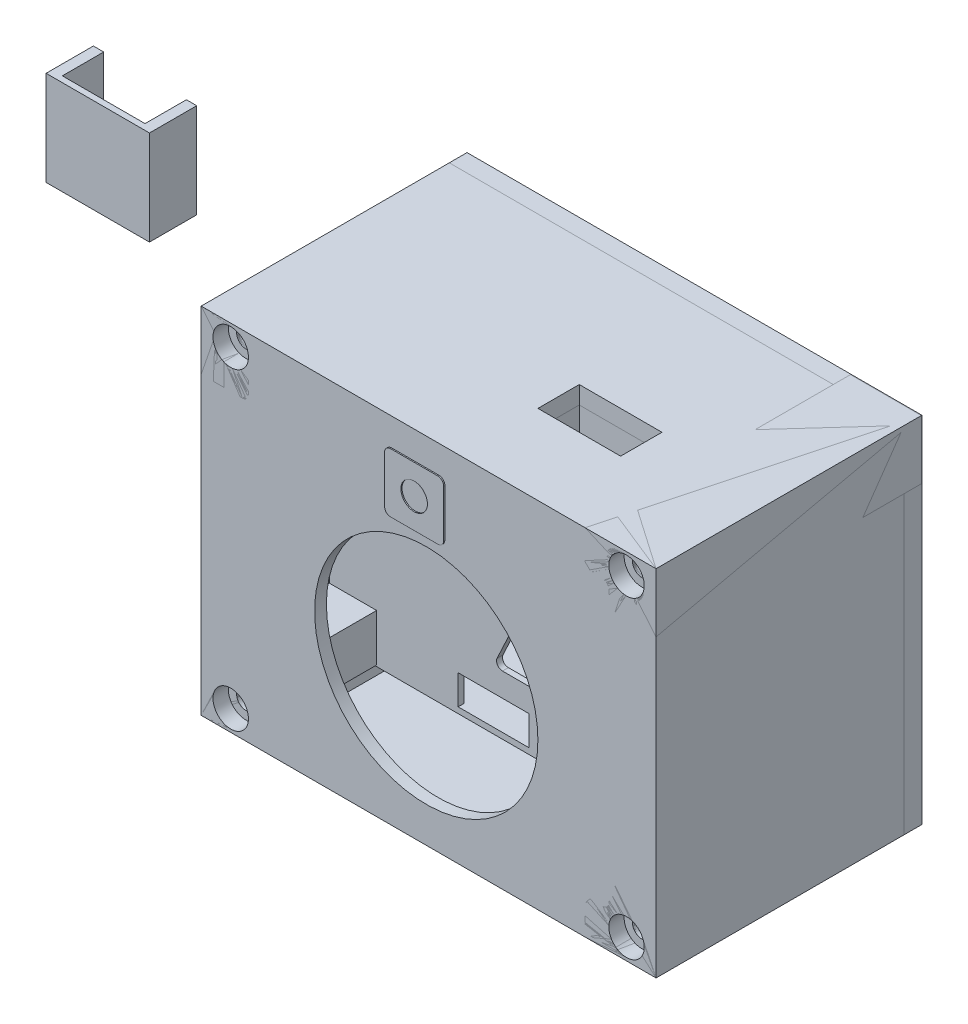
from build123d import *

# Parameters (mm, degrees)
NODEBASESECTION_W                   = 48.4
NODEBASESECTION_H                   = 25.7
NODEBASE_DEPTH                      = 1.7
WIFIMODEMSECTION_W                  = 15
WIFIMODEMSECTION_H                  = 12
WIFIMODEMSECTION_W_2                = 5.7
WIFIMODEMSECTION_H_2                = 7.4
MICROPORT_WIFIMODEM_DEPTH           = 2.7
ANTENNA_DEPTH                       = 0.2
F_4NODEATTACHMENTHOLESSECTION_R     = 1.5
F_4NODEATTACHMENTHOLES_DEPTH        = 2
DSMBLUEPINSSECTION_W                = 6
DSMBLUEPINSSECTION_H                = 6
DSMBLUEPINS_DEPTH                   = 5
DSMBLUEPINS_2_DEPTH                 = 5
PCBSECTION_W                        = 58.8
PCBSECTION_H                        = 44.55
PCB_DEPTH                           = 1.5
BLACKPLASTICCOVER_DEPTH             = 15
BLACKDSMSHELL_T                     = -1
SIDEHOLECUTTERSECTION_W             = 14
SIDEHOLECUTTERSECTION_H             = 7
SIDEHOLECUTTER_DEPTH                = 1.5
F_3HOLESCUTTERSECTION_W             = 12
F_3HOLESCUTTERSECTION_H             = 5
F_3HOLESCUTTER_DEPTH                = 1.5
BOXCAP_TONODE_START                 = -9
BOXCAPSECTION_TONODE_W              = 77
BOXCAPSECTION_TONODE_H              = 60
BOXCAP_TONODE_DEPTH                 = 3
NODESCREWCOLUMNSSECTION_W           = 8
NODESCREWCOLUMNSSECTION_H           = 8
NODESCREWCOLUMNS_DEPTH              = 6
BOXCAP_TODSM_START                  = 36
BOXCAPSECTION_TODSM_W               = 77
BOXCAPSECTION_TODSM_H               = 60
BOXCAP_TODSM_DEPTH                  = 42
HOLLOWBOXCAP_TODSM_T                = -3
DSMLEGSSECTION_W                    = 8
DSMLEGSSECTION_H                    = 8
DSMLEGSSECTION_H_2                  = 5.5
DSMLEGS_DEPTH                       = 9.5
FANCUTTERSECTION_R                  = 18.9
FANCUTTER_DEPTH                     = 3
SQUAREFANBODYCUTTER_START           = -2
SQUAREFANBODYCUTTER_DEPTH           = 3
EXHAUSTDUCT_DEPTH                   = 16
EXHAUSTHOLECUTTERSECTION_W          = 14
EXHAUSTHOLECUTTERSECTION_H          = 7
EXHAUSTHOLECUTTER_DEPTH             = 5
SCREWDSMHOLECUTTERSECTION_R         = 2.25
SCREWDSMHOLECUTTER_DEPTH            = 2
MICROUSBHOLECUTTER_DEPTH            = 3
EXHAUSTHOLEDUCTSECTION_W            = 16
EXHAUSTHOLEDUCTSECTION_H            = 9
EXHAUSTHOLEDUCTSECTION_W_2          = 14
EXHAUSTHOLEDUCTSECTION_H_2          = 7
EXHAUSTHOLEDUCT_DEPTH               = 12
DSMPCBSCREWHOLESECTION_R            = 2.25
DSMPCBSCREWHOLE_DEPTH               = 27.7
DSMPCBSCREWHOLEADDITIONAL_DEPTH     = 1.5
BOXCLOSINGSCREWCOLUMNS_DEPTH        = 44.9
BOXCLOSINGSCREWCOLUMNS_2_DEPTH      = 44.9
BOXCLOSINGSCREWCOLUMNS_3_DEPTH      = 44.9
BOXCLOSINGSCREWCOLUMNS_4_DEPTH      = 44.9
BOXCLOSINGSCREWHOLESCUTTERSECTION_R = 1.6
BOXCLOSINGSCREWHOLESCUTTER_DEPTH    = 45.9
NUTCUTTER_DEPTH                     = 2.3
SCREWHEADBEDCUTTERSECTION_R         = 3
SCREWHEADBEDCUTTER_DEPTH            = 2.6


with BuildPart() as part:
    # NodeBaseSection → NodeBase (new body)
    with BuildSketch(Plane.XY):
        with Locations((-24.2, 12.85)):
            Rectangle(NODEBASESECTION_W, NODEBASESECTION_H)
    extrude(amount=NODEBASE_DEPTH)

    # WiFiModemSection → MicroPort+WiFiModem (add)
    with BuildSketch(Plane.XY):
        with Locations((-15.1, 12.85)):
            Rectangle(WIFIMODEMSECTION_W, WIFIMODEMSECTION_H)
        with Locations((-46.35, 12.85)):
            Rectangle(WIFIMODEMSECTION_W_2, WIFIMODEMSECTION_H_2)
    extrude(amount=MICROPORT_WIFIMODEM_DEPTH)

    # AntennaSection → Antenna (add)
    with BuildSketch(Plane.XY.offset(1.7)):
        Polygon((-6.6, 7.8), (-6.6, 18.2), (-0.8, 18.2), (-0.8, 15.8), (-4.4420087, 15.8), (-4.4420087, 15), (-0.8, 15), (-0.8, 12.6), (-4.4420087, 12.6), (-4.4420087, 11.8), (-0.8, 11.8), (-0.8, 9.4), (-4.4420087, 9.4), (-4.4420087, 8.6), (-0.8, 8.6), (-0.8, 4.6), (-1.6, 4.6), (-1.6, 7.8), (-5.2420087, 7.8), (-5.2420087, 10.2), (-1.6, 10.2), (-1.6, 11), (-5.2420087, 11), (-5.2420087, 13.4), (-1.6, 13.4), (-1.6, 14.2), (-5.2420087, 14.2), (-5.2420087, 16.6), (-1.6, 16.6), (-1.6, 17.4), (-5.8, 17.4), (-5.8, 7.8), align=None)
    extrude(amount=ANTENNA_DEPTH)


with BuildPart() as part_1:
    # MovedWholeNode: moved
    add(part.part.moved(Location((72.4, -2.35, 0))))

    # 4NodeAttachmentHolesSection → 4NodeAttachmentHoles (cut)
    with BuildSketch(Plane(origin=(0, 0, 0), x_dir=(-1, 0, 0), z_dir=(0, 0, -1))):
        with Locations((-69.9, 0.05)):
            Circle(F_4NODEATTACHMENTHOLESSECTION_R)
        with Locations((-69.9, 20.95)):
            Circle(F_4NODEATTACHMENTHOLESSECTION_R)
        with Locations((-26.1, 20.95)):
            Circle(F_4NODEATTACHMENTHOLESSECTION_R)
        with Locations((-26.1, 0.05)):
            Circle(F_4NODEATTACHMENTHOLESSECTION_R)
    extrude(amount=-F_4NODEATTACHMENTHOLES_DEPTH, mode=Mode.SUBTRACT)



with BuildPart() as body_2:
    # DSMBluePinsSection → DSMBluePins (new body)
    with BuildSketch(Plane.XY):
        with Locations((-17.5, 40.05)):
            Rectangle(DSMBLUEPINSSECTION_W, DSMBLUEPINSSECTION_H)
    extrude(amount=DSMBLUEPINS_DEPTH)



with BuildPart() as body_3:
    # DSMBluePinsSection → DSMBluePins 2 (new body)
    with BuildSketch(Plane.XY):
        with Locations((-7.5, 40.05)):
            Rectangle(DSMBLUEPINSSECTION_W, DSMBLUEPINSSECTION_H)
    extrude(amount=DSMBLUEPINS_2_DEPTH)


with BuildPart() as body_2_1:
    add(body_2.part)

    add(body_3.part)  # PCB merges body 3
    # PCBSection → PCB (add)
    with BuildSketch(Plane.XY):
        with Locations((-29.4, 22.275)):
            Rectangle(PCBSECTION_W, PCBSECTION_H)
    extrude(amount=-PCB_DEPTH)


with BuildPart() as body_3_2:
    # BlackPlasticCoverSection → BlackPlasticCover (new body)
    with BuildSketch(Plane.XY):
        Polygon((0, 1), (-58.8, 1), (-58.8, 36.5), (-50.5, 43.3), (-36.6, 36.5), (0, 36.5), (0, 13), (-4.5, 13), (-4.5, 8), (-2, 8), (-2, 7), (0, 7), align=None)
    extrude(amount=BLACKPLASTICCOVER_DEPTH)

    # BlackDSMShell
    blackdsmshell_openings = [body_3_2.faces().sort_by_distance(p)[0] for p in [
        (-30.391127396, 19.553871622, 0),
    ]]
    offset(amount=BLACKDSMSHELL_T, openings=blackdsmshell_openings, kind=Kind.INTERSECTION)

    # SideHoleCutterSection → SideHoleCutter (cut)
    with BuildSketch(Plane(origin=(0, 36.5, 0), x_dir=(1, 0, 0), z_dir=(0, 1, 0))):
        with Locations((-17.5, -10.5)):
            Rectangle(SIDEHOLECUTTERSECTION_W, SIDEHOLECUTTERSECTION_H)
    extrude(amount=-SIDEHOLECUTTER_DEPTH, mode=Mode.SUBTRACT)

    # 3HolesCutterSection → 3HolesCutter (cut)
    with BuildSketch(Plane.XY.offset(15)):
        Polygon((-6.5, 17), (-11.696152423, 14), (-13.946152423, 17.897114317), (-8.75, 20.897114317), align=None)
        with Locations((-31, 4.5)):
            Rectangle(F_3HOLESCUTTERSECTION_W, F_3HOLESCUTTERSECTION_H)
        with BuildLine():
            Line((-21, 11), (-29.5, 11))
            ThreePointArc((-29.5, 11), (-30.343527392, 11.462913844), (-30.406093768, 12.423076923))
            Line((-30.406093768, 12.423076923), (-24.906093768, 24.202295912))
            ThreePointArc((-24.906093768, 24.202295912), (-24.537086156, 24.622746382), (-24, 24.779218989))
            Line((-24, 24.779218989), (-21, 24.779218989))
            ThreePointArc((-21, 24.779218989), (-20.292893219, 24.486325771), (-20, 23.779218989))
            Line((-20, 23.779218989), (-20, 12))
            ThreePointArc((-20, 12), (-20.292893219, 11.292893219), (-21, 11))
        make_face()
    extrude(amount=-F_3HOLESCUTTER_DEPTH, mode=Mode.SUBTRACT)


with BuildPart() as body_4:
    # BoxCapSection(ToNode) → BoxCap(ToNode) (new body)
    with BuildSketch(Plane.XY.offset(BOXCAP_TONODE_START)):
        with Locations((59.5, 10.5)):
            Rectangle(BOXCAPSECTION_TONODE_W, BOXCAPSECTION_TONODE_H)
    extrude(amount=BOXCAP_TONODE_DEPTH)


with BuildPart() as part_2:
    add(part_1.part)

    add(body_4.part)  # NodeScrewColumns merges body 4
    # NodeScrewColumnsSection → NodeScrewColumns (add)
    with BuildSketch(Plane.XY.offset(-6)):
        with Locations((68.4, 1.85)):
            Rectangle(NODESCREWCOLUMNSSECTION_W, NODESCREWCOLUMNSSECTION_H)
        with Locations((28, 1.85)):
            Rectangle(NODESCREWCOLUMNSSECTION_W, NODESCREWCOLUMNSSECTION_H)
        with Locations((28, 19)):
            Rectangle(NODESCREWCOLUMNSSECTION_W, NODESCREWCOLUMNSSECTION_H)
        with Locations((68.4, 19)):
            Rectangle(NODESCREWCOLUMNSSECTION_W, NODESCREWCOLUMNSSECTION_H)
    extrude(amount=NODESCREWCOLUMNS_DEPTH)


with BuildPart() as body_4_2:
    # BoxCapSection(ToDSM) → BoxCap(ToDSM) (new body)
    with BuildSketch(Plane.XY.offset(BOXCAP_TODSM_START)):
        with Locations((59.5, 10.5)):
            Rectangle(BOXCAPSECTION_TODSM_W, BOXCAPSECTION_TODSM_H)
    extrude(amount=-BOXCAP_TODSM_DEPTH)

    # HollowBoxCap(ToDSM)
    hollowboxcap_todsm_openings = [body_4_2.faces().sort_by_distance(p)[0] for p in [
        (59.5, 10.5, -6),
    ]]
    offset(amount=HOLLOWBOXCAP_TODSM_T, openings=hollowboxcap_todsm_openings, kind=Kind.INTERSECTION)

    # DSMLegsSection → DSMLegs (add)
    with BuildSketch(Plane(origin=(0, 0, 33), x_dir=(-1, 0, 0), z_dir=(0, 0, -1))):
        with Locations((-34.2, -5.77)):
            Rectangle(DSMLEGSSECTION_W, DSMLEGSSECTION_H)
        with Locations((-34.2, 21.5)):
            Rectangle(DSMLEGSSECTION_W, DSMLEGSSECTION_H)
        with Locations((-84.9, -7.02)):
            Rectangle(DSMLEGSSECTION_W, DSMLEGSSECTION_H_2)
        with Locations((-84.9, 21.5)):
            Rectangle(DSMLEGSSECTION_W, DSMLEGSSECTION_H)
    extrude(amount=DSMLEGS_DEPTH)

    # FanCutterSection → FanCutter (cut)
    with BuildSketch(Plane.XY.offset(36)):
        with Locations((59.1, 5.4)):
            Circle(FANCUTTERSECTION_R)
    extrude(amount=-FANCUTTER_DEPTH, mode=Mode.SUBTRACT)

    # SquareFanBodyCutterSection → SquareFanBodyCutter (cut)
    with BuildSketch(Plane.XY.offset(36).offset(SQUAREFANBODYCUTTER_START)):
        with BuildLine():
            Line((42.1, -14.6), (76.1, -14.6))
            ThreePointArc((76.1, -14.6), (78.221320344, -13.721320344), (79.1, -11.6))
            Line((79.1, -11.6), (79.1, 22.4))
            ThreePointArc((79.1, 22.4), (78.221320344, 24.521320344), (76.1, 25.4))
            Line((76.1, 25.4), (42.1, 25.4))
            ThreePointArc((42.1, 25.4), (39.978679656, 24.521320344), (39.1, 22.4))
            Line((39.1, 22.4), (39.1, -11.6))
            ThreePointArc((39.1, -11.6), (39.978679656, -13.721320344), (42.1, -14.6))
        make_face()
    extrude(amount=-SQUAREFANBODYCUTTER_DEPTH, mode=Mode.SUBTRACT)

    # ExhaustHoleCutterSection → ExhaustHoleCutter (cut)
    with BuildSketch(Plane(origin=(0, 40.5, 0), x_dir=(1, 0, 0), z_dir=(0, 1, 0))):
        with Locations((71.5, -19)):
            Rectangle(EXHAUSTHOLECUTTERSECTION_W, EXHAUSTHOLECUTTERSECTION_H)
    extrude(amount=-EXHAUSTHOLECUTTER_DEPTH, mode=Mode.SUBTRACT)

    # MicroUSBHoleCutterSection → MicroUSBHoleCutter (cut)
    with BuildSketch(Plane.ZY.offset(-21)):
        with BuildLine():
            Line((3.6, 16.75), (-0.9, 16.75))
            ThreePointArc((-0.9, 16.75), (-1.607106781, 16.457106781), (-1.9, 15.75))
            Line((-1.9, 15.75), (-1.9, 5.25))
            ThreePointArc((-1.9, 5.25), (-1.607106781, 4.542893219), (-0.9, 4.25))
            Line((-0.9, 4.25), (3.6, 4.25))
            ThreePointArc((3.6, 4.25), (4.307106781, 4.542893219), (4.6, 5.25))
            Line((4.6, 5.25), (4.6, 15.75))
            ThreePointArc((4.6, 15.75), (4.307106781, 16.457106781), (3.6, 16.75))
        make_face()
    extrude(amount=-MICROUSBHOLECUTTER_DEPTH, mode=Mode.SUBTRACT)


with BuildPart() as body_5:
    # ExhaustDuctSection → ExhaustDuct (new body)
    with BuildSketch(Plane(origin=(0, 40.5, 0), x_dir=(1, 0, 0), z_dir=(0, 1, 0))):
        Polygon((-10.5, -7), (-8.75, -7), (-8.75, -15), (-26.25, -15), (-26.25, -7), (-24.5, -7), (-24.5, -14), (-10.5, -14), align=None)
    extrude(amount=-EXHAUSTDUCT_DEPTH)


with BuildPart() as body_3_2_1:
    # DSMModule: moved
    add(body_3_2.part.moved(Location((89, -11, 8.5))))


with BuildPart() as body_2_2:
    # DSMModule: moved
    add(body_2_1.part.moved(Location((89, -11, 8.5))))

    # ScrewDSMHoleCutterSection → ScrewDSMHoleCutter (cut)
    with BuildSketch(Plane.XY.offset(8.5)):
        with Locations((57.25, 30.825)):
            Circle(SCREWDSMHOLECUTTERSECTION_R)
    extrude(amount=-SCREWDSMHOLECUTTER_DEPTH, mode=Mode.SUBTRACT)


with BuildPart() as body_6:
    # ExhaustHoleDuctSection → ExhaustHoleDuct (new body)
    with BuildSketch(Plane(origin=(0, 25.5, 0), x_dir=(1, 0, 0), z_dir=(0, 1, 0))):
        with Locations((71.5, -19)):
            Rectangle(EXHAUSTHOLEDUCTSECTION_W, EXHAUSTHOLEDUCTSECTION_H)
        with Locations((71.5, -19)):
            Rectangle(EXHAUSTHOLEDUCTSECTION_W_2, EXHAUSTHOLEDUCTSECTION_H_2, mode=Mode.SUBTRACT)
    extrude(amount=EXHAUSTHOLEDUCT_DEPTH)


with BuildPart() as body_7:
    # DSMPCBScrewHoleSection → DSMPCBScrewHole (new body)
    with BuildSketch(Plane.XY.offset(8.5)):
        with BuildLine():
            Line((61.25, 25.825), (53.25, 25.825))
            ThreePointArc((53.25, 25.825), (52.542893219, 26.117893219), (52.25, 26.825))
            Line((52.25, 26.825), (52.25, 34.825))
            ThreePointArc((52.25, 34.825), (52.542893219, 35.532106781), (53.25, 35.825))
            Line((53.25, 35.825), (61.25, 35.825))
            ThreePointArc((61.25, 35.825), (61.957106781, 35.532106781), (62.25, 34.825))
            Line((62.25, 34.825), (62.25, 26.825))
            ThreePointArc((62.25, 26.825), (61.957106781, 26.117893219), (61.25, 25.825))
        make_face()
        with Locations((57.25, 30.825)):
            Circle(DSMPCBSCREWHOLESECTION_R, mode=Mode.SUBTRACT)
    extrude(amount=DSMPCBSCREWHOLE_DEPTH)

    # DSMPCBScrewHoleAdditionalSection → DSMPCBScrewHoleAdditional (add)
    with BuildSketch(Plane(origin=(0, 0, 8.5), x_dir=(-1, 0, 0), z_dir=(0, 0, -1))):
        with BuildLine():
            Line((-62.25, 33.55), (-52.25, 33.55))
            Line((-52.25, 33.55), (-52.25, 34.825))
            ThreePointArc((-52.25, 34.825), (-52.542893219, 35.532106781), (-53.25, 35.825))
            Line((-53.25, 35.825), (-61.25, 35.825))
            ThreePointArc((-61.25, 35.825), (-61.957106781, 35.532106781), (-62.25, 34.825))
            Line((-62.25, 34.825), (-62.25, 33.55))
        make_face()
    extrude(amount=DSMPCBSCREWHOLEADDITIONAL_DEPTH)


with BuildPart() as body_8:
    # BoxClosingScrewColumnsSection → BoxClosingScrewColumns (new body)
    with BuildSketch(Plane.XY.offset(36)):
        with BuildLine():
            Line((21, 30.5), (21, 40.5))
            Line((21, 40.5), (33, 40.5))
            Line((33, 40.5), (33, 35.5))
            ThreePointArc((33, 35.5), (32.707106781, 34.792893219), (32, 34.5))
            Line((32, 34.5), (30, 34.5))
            ThreePointArc((30, 34.5), (29.292893219, 34.207106781), (29, 33.5))
            Line((29, 33.5), (29, 31.5))
            ThreePointArc((29, 31.5), (28.707106781, 30.792893219), (28, 30.5))
            Line((28, 30.5), (21, 30.5))
        make_face()
    extrude(amount=-BOXCLOSINGSCREWCOLUMNS_DEPTH)


with BuildPart() as body_9:
    # BoxClosingScrewColumnsSection → BoxClosingScrewColumns 2 (new body)
    with BuildSketch(Plane.XY.offset(36)):
        with BuildLine():
            Line((98, 30.5), (98, 40.5))
            Line((98, 40.5), (86, 40.5))
            Line((86, 40.5), (86, 35.5))
            ThreePointArc((86, 35.5), (86.292893219, 34.792893219), (87, 34.5))
            Line((87, 34.5), (89, 34.5))
            ThreePointArc((89, 34.5), (89.707106781, 34.207106781), (90, 33.5))
            Line((90, 33.5), (90, 31.5))
            ThreePointArc((90, 31.5), (90.292893219, 30.792893219), (91, 30.5))
            Line((91, 30.5), (98, 30.5))
        make_face()
    extrude(amount=-BOXCLOSINGSCREWCOLUMNS_2_DEPTH)


with BuildPart() as body_10:
    # BoxClosingScrewColumnsSection → BoxClosingScrewColumns 3 (new body)
    with BuildSketch(Plane.XY.offset(36)):
        with BuildLine():
            Line((91, -9.5), (98, -9.5))
            Line((98, -9.5), (98, -19.5))
            Line((98, -19.5), (86, -19.5))
            Line((86, -19.5), (86, -14.5))
            ThreePointArc((86, -14.5), (86.292893219, -13.792893219), (87, -13.5))
            Line((87, -13.5), (89, -13.5))
            ThreePointArc((89, -13.5), (89.707106781, -13.207106781), (90, -12.5))
            Line((90, -12.5), (90, -10.5))
            ThreePointArc((90, -10.5), (90.292893219, -9.792893219), (91, -9.5))
        make_face()
    extrude(amount=-BOXCLOSINGSCREWCOLUMNS_3_DEPTH)


with BuildPart() as body_11:
    # BoxClosingScrewColumnsSection → BoxClosingScrewColumns 4 (new body)
    with BuildSketch(Plane.XY.offset(36)):
        with BuildLine():
            Line((33, -14.5), (33, -19.5))
            Line((33, -19.5), (21, -19.5))
            Line((21, -19.5), (21, -9.5))
            Line((21, -9.5), (28, -9.5))
            ThreePointArc((28, -9.5), (28.707106781, -9.792893219), (29, -10.5))
            Line((29, -10.5), (29, -12.5))
            ThreePointArc((29, -12.5), (29.292893219, -13.207106781), (30, -13.5))
            Line((30, -13.5), (32, -13.5))
            ThreePointArc((32, -13.5), (32.707106781, -13.792893219), (33, -14.5))
        make_face()
    extrude(amount=-BOXCLOSINGSCREWCOLUMNS_4_DEPTH)


with BuildPart() as boxclosingscrewholescutter_tool:
    # BoxClosingScrewHolesCutterSection → BoxClosingScrewHolesCutter (new body)
    with BuildSketch(Plane.XY.offset(36)):
        with Locations((26, 37)):
            Circle(BOXCLOSINGSCREWHOLESCUTTERSECTION_R)
        with Locations((93, 37)):
            Circle(BOXCLOSINGSCREWHOLESCUTTERSECTION_R)
        with Locations(Location((93, -16, 0), (0, 0, 180))):
            Circle(BOXCLOSINGSCREWHOLESCUTTERSECTION_R)
        with Locations((26, -16)):
            Circle(BOXCLOSINGSCREWHOLESCUTTERSECTION_R)
    extrude(amount=-BOXCLOSINGSCREWHOLESCUTTER_DEPTH)


with BuildPart() as part_3:
    add(part_2.part)

    # BoxClosingScrewHolesCutter: cut by boxclosingscrewholescutter_tool
    add(boxclosingscrewholescutter_tool.part, mode=Mode.SUBTRACT)


with BuildPart() as body_4_2_1:
    add(body_4_2.part)

    # BoxClosingScrewHolesCutter: cut by boxclosingscrewholescutter_tool
    add(boxclosingscrewholescutter_tool.part, mode=Mode.SUBTRACT)


with BuildPart() as body_8_1:
    add(body_8.part)

    # BoxClosingScrewHolesCutter: cut by boxclosingscrewholescutter_tool
    add(boxclosingscrewholescutter_tool.part, mode=Mode.SUBTRACT)


with BuildPart() as body_9_1:
    add(body_9.part)

    # BoxClosingScrewHolesCutter: cut by boxclosingscrewholescutter_tool
    add(boxclosingscrewholescutter_tool.part, mode=Mode.SUBTRACT)


with BuildPart() as body_10_1:
    add(body_10.part)

    # BoxClosingScrewHolesCutter: cut by boxclosingscrewholescutter_tool
    add(boxclosingscrewholescutter_tool.part, mode=Mode.SUBTRACT)


with BuildPart() as body_11_1:
    add(body_11.part)

    # BoxClosingScrewHolesCutter: cut by boxclosingscrewholescutter_tool
    add(boxclosingscrewholescutter_tool.part, mode=Mode.SUBTRACT)


with BuildPart() as nutcutter_tool:
    # NutCutterSection → NutCutter (new body)
    with BuildSketch(Plane(origin=(0, 0, -9), x_dir=(-1, 0, 0), z_dir=(0, 0, -1))):
        Polygon((-27.616580754, 34.2), (-24.383419246, 34.2), (-22.766838493, 37), (-24.383419246, 39.8), (-27.616580754, 39.8), (-29.233161507, 37), align=None)
        Polygon((-89.766838493, 37), (-91.383419246, 39.8), (-94.616580754, 39.8), (-96.233161507, 37), (-94.616580754, 34.2), (-91.383419246, 34.2), align=None)
        Polygon((-91.383419246, -13.2), (-89.766838493, -16), (-91.383419246, -18.8), (-94.616580754, -18.8), (-96.233161507, -16), (-94.616580754, -13.2), align=None)
        Polygon((-29.233161507, -16), (-27.616580754, -13.2), (-24.383419246, -13.2), (-22.766838493, -16), (-24.383419246, -18.8), (-27.616580754, -18.8), align=None)
    extrude(amount=-NUTCUTTER_DEPTH)


with BuildPart() as part_4:
    add(part_3.part)

    # NutCutter: cut by nutcutter_tool
    add(nutcutter_tool.part, mode=Mode.SUBTRACT)


with BuildPart() as body_8_2:
    add(body_8_1.part)

    # NutCutter: cut by nutcutter_tool
    add(nutcutter_tool.part, mode=Mode.SUBTRACT)


with BuildPart() as body_9_2:
    add(body_9_1.part)

    # NutCutter: cut by nutcutter_tool
    add(nutcutter_tool.part, mode=Mode.SUBTRACT)


with BuildPart() as body_10_2:
    add(body_10_1.part)

    # NutCutter: cut by nutcutter_tool
    add(nutcutter_tool.part, mode=Mode.SUBTRACT)


with BuildPart() as body_11_2:
    add(body_11_1.part)

    # NutCutter: cut by nutcutter_tool
    add(nutcutter_tool.part, mode=Mode.SUBTRACT)


with BuildPart() as screwheadbedcutter_tool:
    # ScrewHeadBedCutterSection → ScrewHeadBedCutter (new body)
    with BuildSketch(Plane.XY.offset(36)):
        with Locations((93, -16)):
            Circle(SCREWHEADBEDCUTTERSECTION_R)
        with Locations((26, -16)):
            Circle(SCREWHEADBEDCUTTERSECTION_R)
        with Locations((26, 37)):
            Circle(SCREWHEADBEDCUTTERSECTION_R)
        with Locations((93, 37)):
            Circle(SCREWHEADBEDCUTTERSECTION_R)
    extrude(amount=-SCREWHEADBEDCUTTER_DEPTH)


with BuildPart() as body_4_2_2:
    add(body_4_2_1.part)

    # ScrewHeadBedCutter: cut by screwheadbedcutter_tool
    add(screwheadbedcutter_tool.part, mode=Mode.SUBTRACT)


with BuildPart() as body_8_3:
    add(body_8_2.part)

    # ScrewHeadBedCutter: cut by screwheadbedcutter_tool
    add(screwheadbedcutter_tool.part, mode=Mode.SUBTRACT)


with BuildPart() as body_9_3:
    add(body_9_2.part)

    # ScrewHeadBedCutter: cut by screwheadbedcutter_tool
    add(screwheadbedcutter_tool.part, mode=Mode.SUBTRACT)


with BuildPart() as body_10_3:
    add(body_10_2.part)

    # ScrewHeadBedCutter: cut by screwheadbedcutter_tool
    add(screwheadbedcutter_tool.part, mode=Mode.SUBTRACT)


with BuildPart() as body_11_3:
    add(body_11_2.part)

    # ScrewHeadBedCutter: cut by screwheadbedcutter_tool
    add(screwheadbedcutter_tool.part, mode=Mode.SUBTRACT)


solid = Compound([body_5.part, body_3_2_1.part, body_2_2.part, body_6.part, body_7.part, part_4.part, body_4_2_2.part, body_8_3.part, body_9_3.part, body_10_3.part, body_11_3.part])
